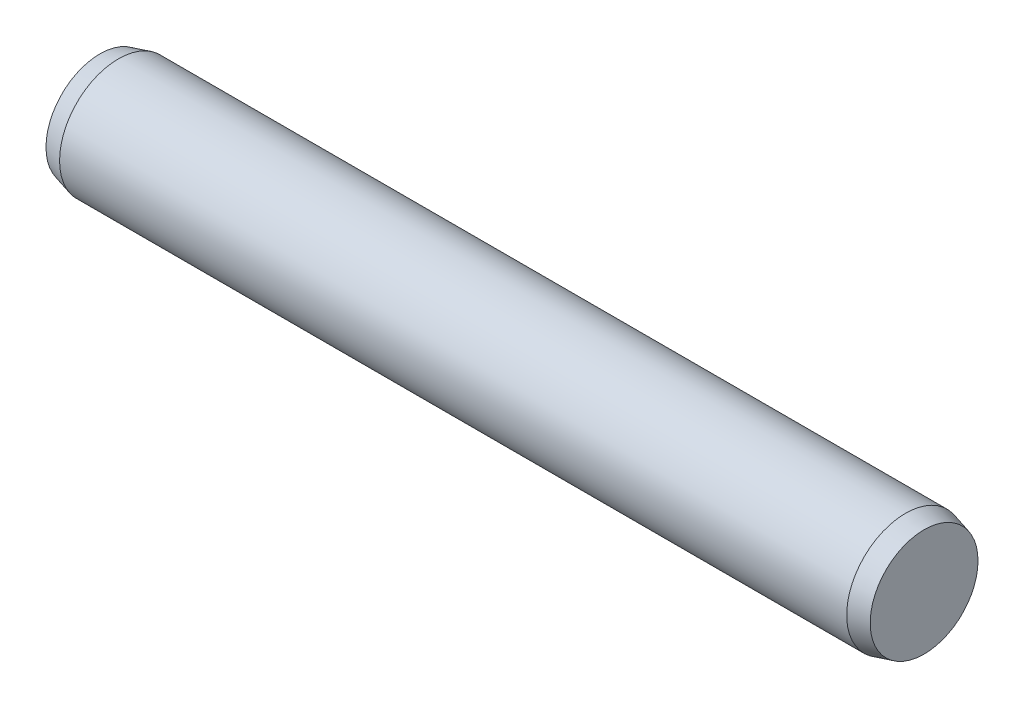
from build123d import *

# Parameters (mm, degrees)
SKETCH2_R           = 2
EXTRUDE1_DEPTH      = 13.37
EXTRUDE1_DEPTH_BACK = 13.37
SKETCH3_R           = 2
EXTRUDE2_DEPTH      = 0.63
EXTRUDE2_TAPER      = 15
SKETCH4_R           = 2
EXTRUDE3_DEPTH      = 0.63
EXTRUDE3_TAPER      = 15


with BuildPart() as part:
    # Sketch2 → Extrude1 (new body, two sides)
    with BuildSketch(Plane(origin=(0, 0, 0), x_dir=(0, 0, -1), z_dir=(1, 0, 0))) as extrude1_sk:
        Circle(SKETCH2_R)
    extrude(amount=EXTRUDE1_DEPTH)
    extrude(extrude1_sk.sketch, amount=-EXTRUDE1_DEPTH_BACK)

    # Sketch3 → Extrude2 (add)
    with BuildSketch(Plane(origin=(13.37, 0, 0), x_dir=(0, 0, -1), z_dir=(1, 0, 0))):
        Circle(SKETCH3_R)
    extrude(amount=EXTRUDE2_DEPTH, taper=EXTRUDE2_TAPER)

    # Sketch4 → Extrude3 (add)
    with BuildSketch(Plane.ZY.offset(13.37)):
        Circle(SKETCH4_R)
    extrude(amount=EXTRUDE3_DEPTH, taper=EXTRUDE3_TAPER)


solid = part.part
